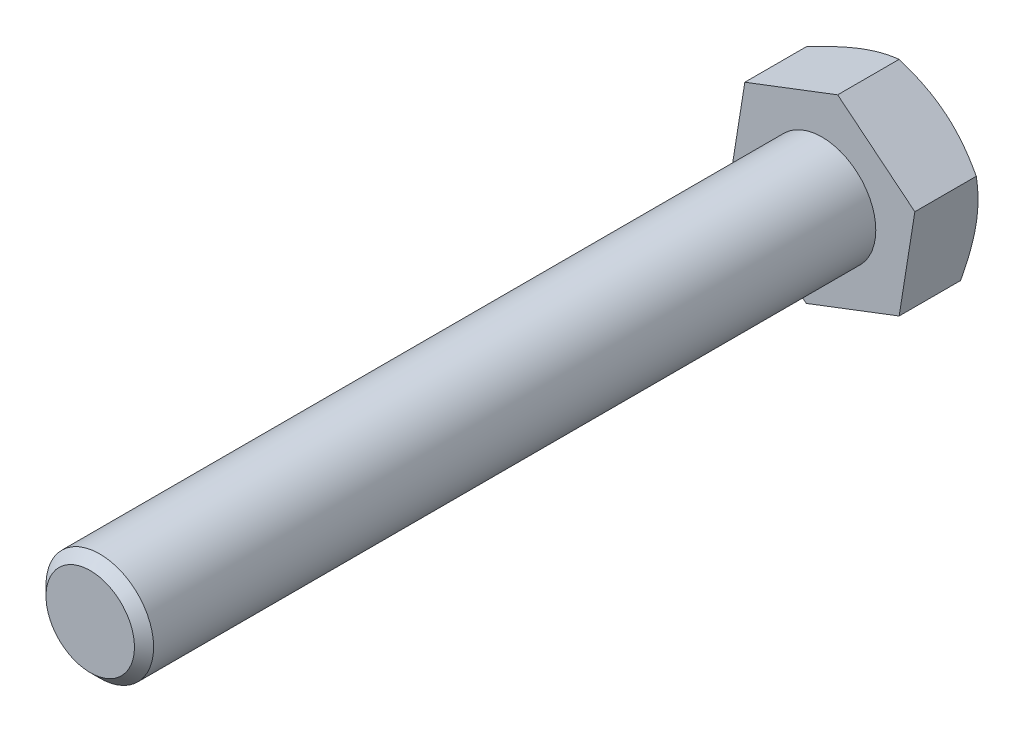
from build123d import *

# Parameters (mm, degrees)
EXTRUDE_1_DEPTH = 3.5
SKETCH_2_R      = 2.5
EXTRUDE_2_DEPTH = 34
CHAMFER_1_SIZE  = 0.445


with BuildPart() as part:
    # Эскиз1 → Бобышка-Вытянуть1 (new body)
    with BuildSketch(Plane.XY):
        Polygon((0.728296009, 4.561021624), (-3.585812589, 2.911233657), (-4.314108598, -1.649787967), (-0.728296009, -4.561021624), (3.585812589, -2.911233657), (4.314108598, 1.649787967), align=None)
    extrude(amount=EXTRUDE_1_DEPTH)

    # Эскиз2 → Бобышка-Вытянуть2 (add)
    with BuildSketch(Plane.XY.offset(3.5)):
        Circle(SKETCH_2_R)
    extrude(amount=EXTRUDE_2_DEPTH)

    # Фаска1
    chamfer_1_edges = [part.edges().sort_by_distance(p)[0] for p in [
        (-2.5, 0, 37.5),
    ]]
    chamfer(chamfer_1_edges, length=CHAMFER_1_SIZE)

    # Эскиз4 → Вырез-Повернуть1 (revolve, cut)
    with BuildSketch(Plane(origin=(0, 0, 0), x_dir=(1, 0, 0), z_dir=(0, 1, 0))):
        Polygon((3.5, 0), (7.5, 0), (7.5, -2.309401077), align=None)
    revolve(axis=Axis((0, 0, 0), (0, 0, 1)), mode=Mode.SUBTRACT)


solid = part.part
